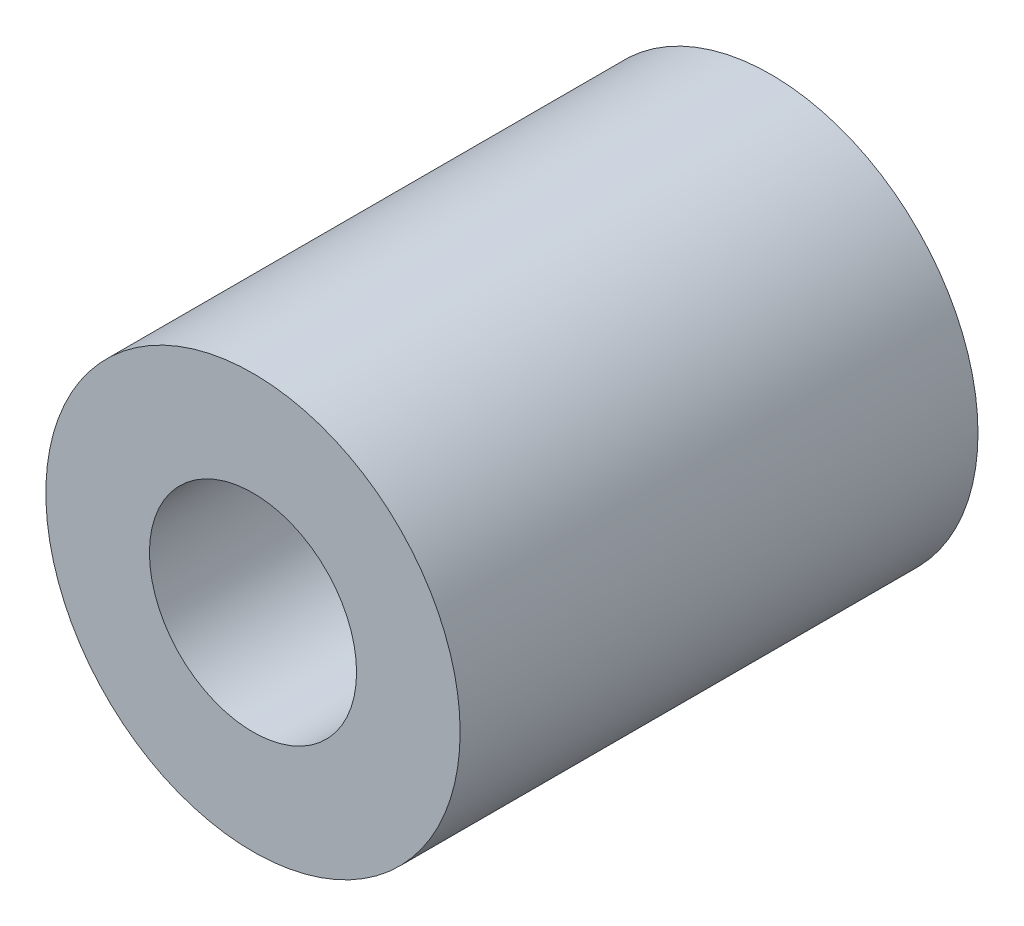
from build123d import *

# Parameters (mm, degrees)
BASE_SKETCH_R     = 2
BASE_SKETCH_R_2   = 1
EXTRUDE_PIN_DEPTH = 5


with BuildPart() as part:
    # Base Sketch → Extrude Pin (new body)
    with BuildSketch(Plane.XY):
        Circle(BASE_SKETCH_R)
        Circle(BASE_SKETCH_R_2, mode=Mode.SUBTRACT)
    extrude(amount=EXTRUDE_PIN_DEPTH)


solid = part.part
